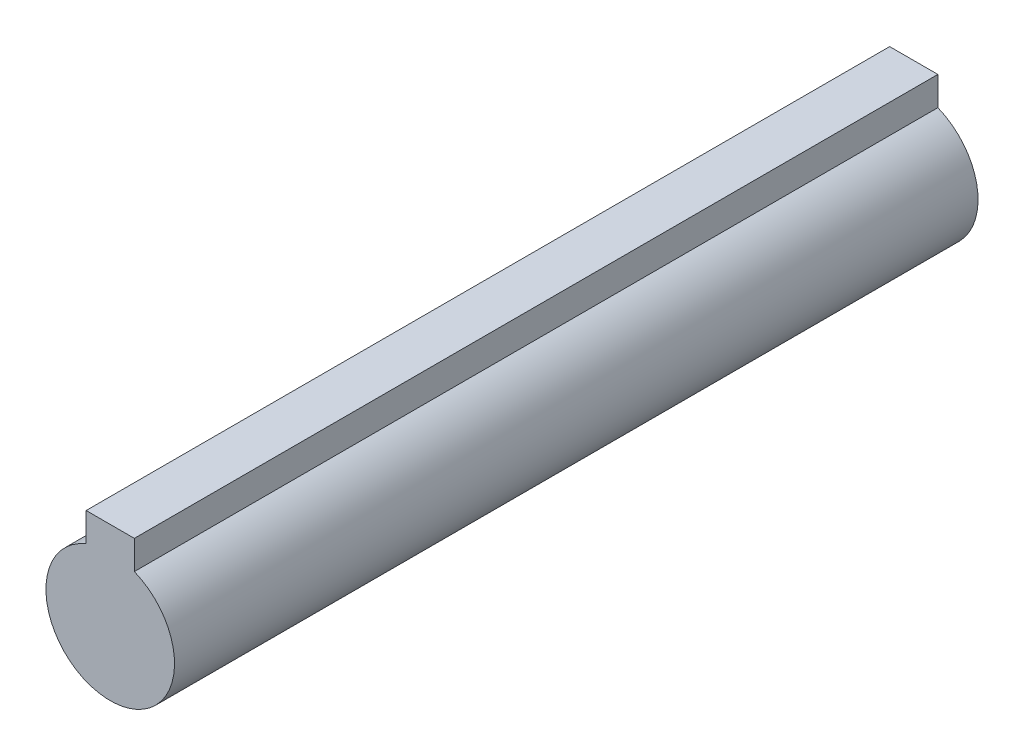
from build123d import *

# Parameters (mm, degrees)
SKETCH1_R           = 4
SKETCH1_W           = 3
SKETCH1_H           = 3
BOSS_EXTRUDE1_DEPTH = 25


with BuildPart() as part:
    # Sketch1 → Boss-Extrude1 (new body, symmetric)
    with BuildSketch(Plane.XY):
        Circle(SKETCH1_R)
        with Locations((0, 4)):
            Rectangle(SKETCH1_W, SKETCH1_H)
    extrude(amount=BOSS_EXTRUDE1_DEPTH, both=True)


solid = part.part
